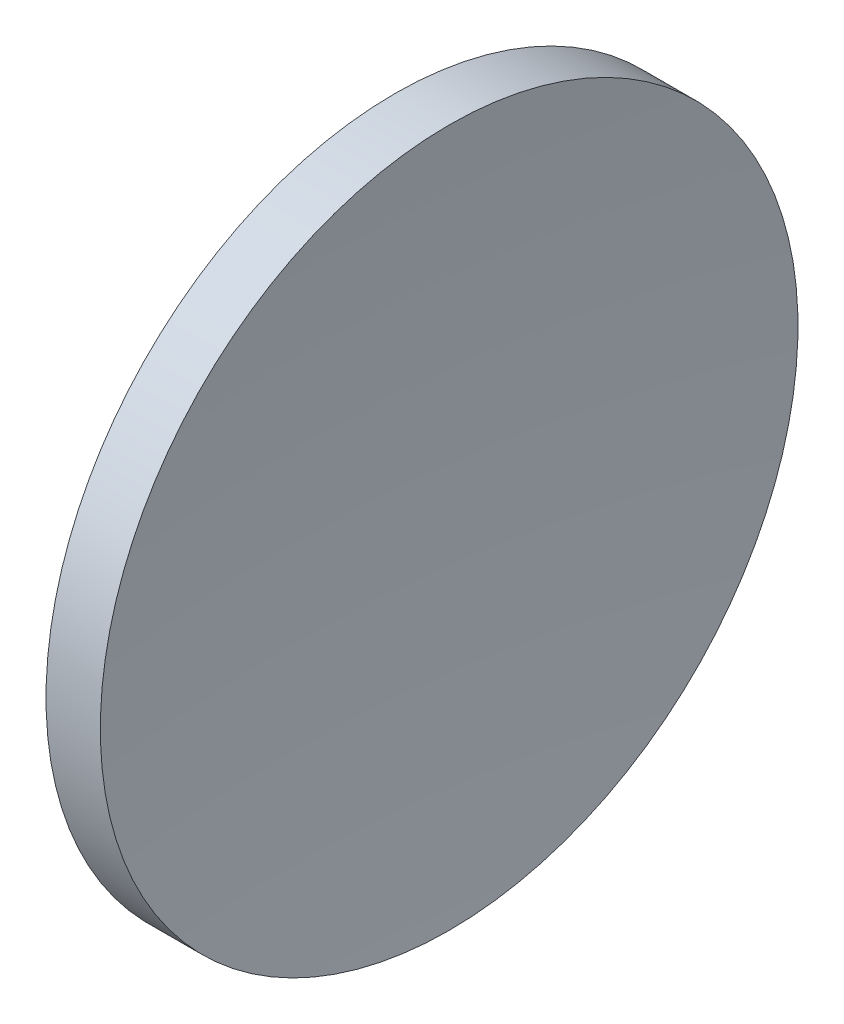
from build123d import *


with BuildPart() as part:
    # 草图1 → 旋转1 (revolve)
    with BuildSketch(Plane.XY):
        with BuildLine():
            Line((125.613306041, 84.241840471), (128.575056939, 84.241840471))
            ThreePointArc((128.575056939, 84.241840471), (127.810513007, 74.742992393), (127.555421316, 65.216840471))
            Line((127.555421316, 65.216840471), (122.855421316, 65.216840471))
            ThreePointArc((122.855421316, 65.216840471), (123.548477021, 74.828767348), (125.613306041, 84.241840471))
        make_face()
    revolve(axis=Axis((115.944491298, 65.216840471, 0), (1, 0, 0)))


solid = part.part
